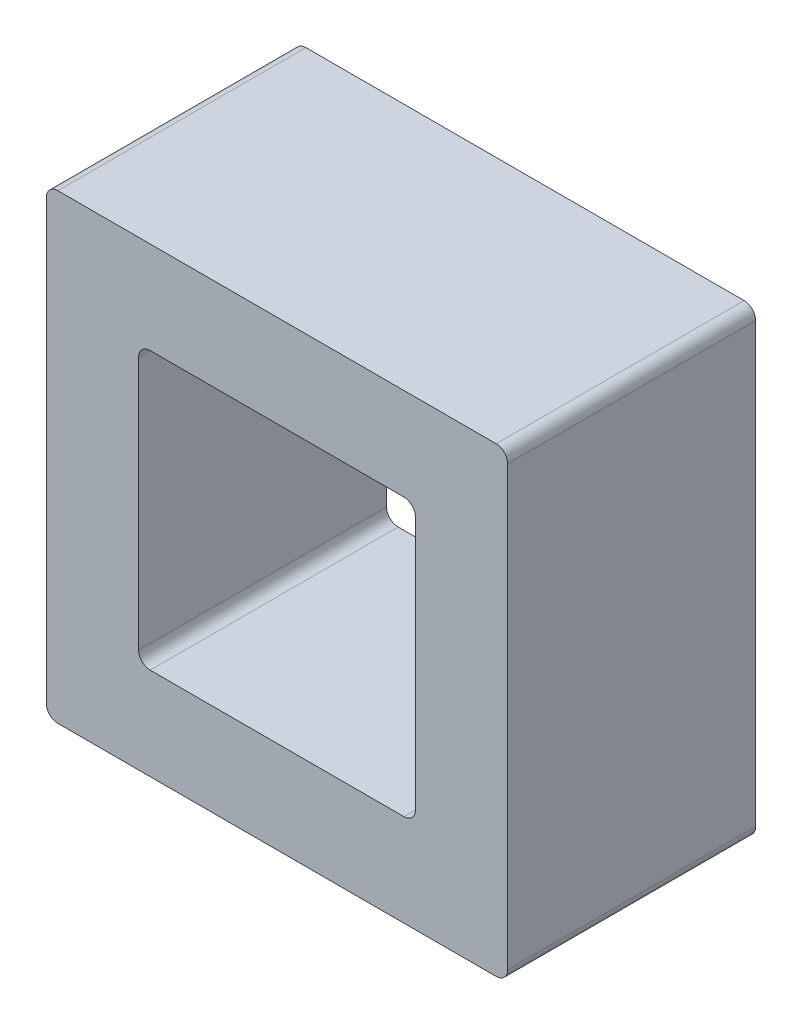
from build123d import *

# Parameters (mm, degrees)
SKETCH1_W           = 8
SKETCH1_H           = 8
SKETCH1_W_2         = 4.8
SKETCH1_H_2         = 4.8
BOSS_EXTRUDE1_DEPTH = 4.3
FILLET1_R           = 0.2


with BuildPart() as part:
    # Sketch1 → Boss-Extrude1 (new body)
    with BuildSketch(Plane.XY):
        with Locations((4, 4)):
            Rectangle(SKETCH1_W, SKETCH1_H)
        with Locations((4, 4)):
            Rectangle(SKETCH1_W_2, SKETCH1_H_2, mode=Mode.SUBTRACT)
    extrude(amount=BOSS_EXTRUDE1_DEPTH)

    # Fillet1
    fillet1_edges = [part.edges().sort_by_distance(p)[0] for p in [
        (1.6, 6.4, 2.15),
        (1.6, 1.6, 2.15),
        (6.4, 1.6, 2.15),
        (6.4, 6.4, 2.15),
        (0, 8, 2.15),
        (8, 8, 2.15),
        (8, 0, 2.15),
        (0, 0, 2.15),
    ]]
    fillet(fillet1_edges, radius=FILLET1_R)


solid = part.part
